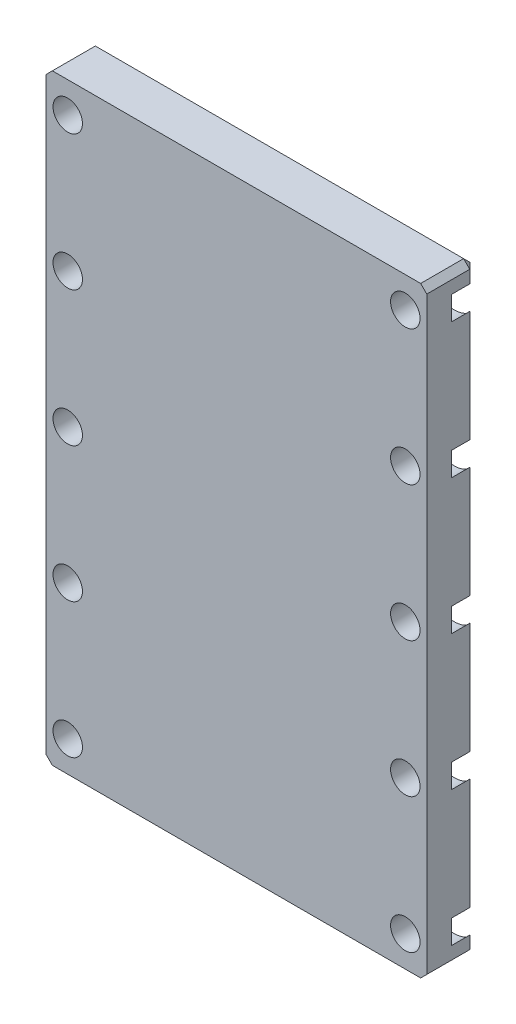
from build123d import *

# Parameters (mm, degrees)
SKETCH_1_W                   = 62
SKETCH_1_H                   = 98
EXTRUDE_1_DEPTH              = 8
CHAMFER_1_SIZE               = 1
HOLE_WIZARD_M4_1_D           = 4.8
HOLE_WIZARD_M4_1_CBORE_D     = 8
HOLE_WIZARD_M4_1_CBORE_DEPTH = 4
MIRROR_2_COPY_1_D            = 4.8
MIRROR_2_COPY_1_CBORE_D      = 8
MIRROR_2_COPY_1_CBORE_DEPTH  = 4


with BuildPart() as part:
    # ｽｹｯﾁ1 → ﾎﾞｽ - 押し出し1 (new body)
    with BuildSketch(Plane.XY):
        Rectangle(SKETCH_1_W, SKETCH_1_H)
    extrude(amount=EXTRUDE_1_DEPTH)

    # 面取り1
    chamfer_1_edges = [part.edges().sort_by_distance(p)[0] for p in [
        (0, -49, 0),
        (-31, 0, 0),
        (0, 49, 0),
        (31, 0, 0),
        (31, -49, 4),
        (-31, -49, 4),
        (-31, 49, 4),
        (31, 49, 4),
    ]]
    chamfer(chamfer_1_edges, length=CHAMFER_1_SIZE)

    # M4 穴付きねじ用座ぐり穴1 (through all)
    with Locations(Plane(origin=(0, 0, 0), x_dir=(1, 0, 0), z_dir=(0, 0, -1))):
        with Locations((-27.5, -44), (-27.5, -22), (-27.5, 0)):
            hole_wizard_m4_1 = CounterBoreHole(HOLE_WIZARD_M4_1_D / 2, HOLE_WIZARD_M4_1_CBORE_D / 2, HOLE_WIZARD_M4_1_CBORE_DEPTH)

    # ﾐﾗｰ1: M4 穴付きねじ用座ぐり穴1 across plane
    add(hole_wizard_m4_1.mirror(Plane.ZX), mode=Mode.SUBTRACT)

    # ﾐﾗｰ2: M4 穴付きねじ用座ぐり穴1 across plane
    add(hole_wizard_m4_1.mirror(Plane(origin=(0, 0, 0), x_dir=(0, 0, 1), z_dir=(1, 0, 0))), mode=Mode.SUBTRACT)

    # ﾐﾗｰ2 copy 1 (through all)
    with Locations(Plane(origin=(0, 0, 0), x_dir=(-1, 0, 0), z_dir=(0, 0, -1))):
        with Locations((-27.5, -44), (-27.5, -22), (-27.5, 0)):
            CounterBoreHole(MIRROR_2_COPY_1_D / 2, MIRROR_2_COPY_1_CBORE_D / 2, MIRROR_2_COPY_1_CBORE_DEPTH)


solid = part.part
